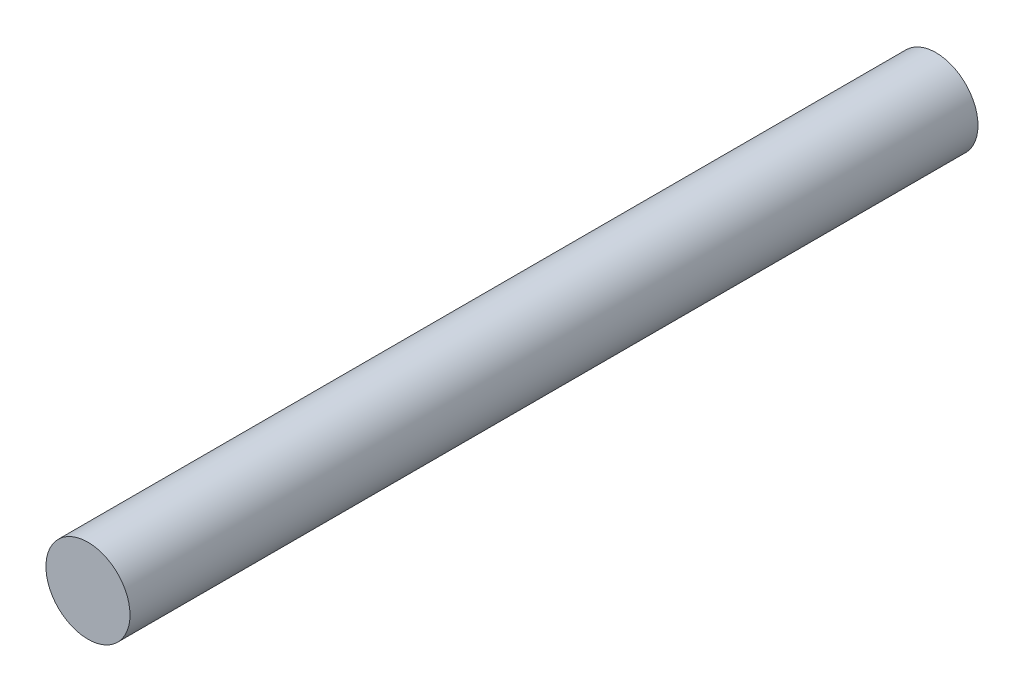
from build123d import *

# Parameters (mm, degrees)
SKIZZE1_R                       = 6
AUFSATZ_LINEAR_AUSTRAGEN1_DEPTH = 121


with BuildPart() as part:
    # Skizze1 → Aufsatz-Linear austragen1 (new body)
    with BuildSketch(Plane.XY):
        Circle(SKIZZE1_R)
    extrude(amount=AUFSATZ_LINEAR_AUSTRAGEN1_DEPTH)


solid = part.part
